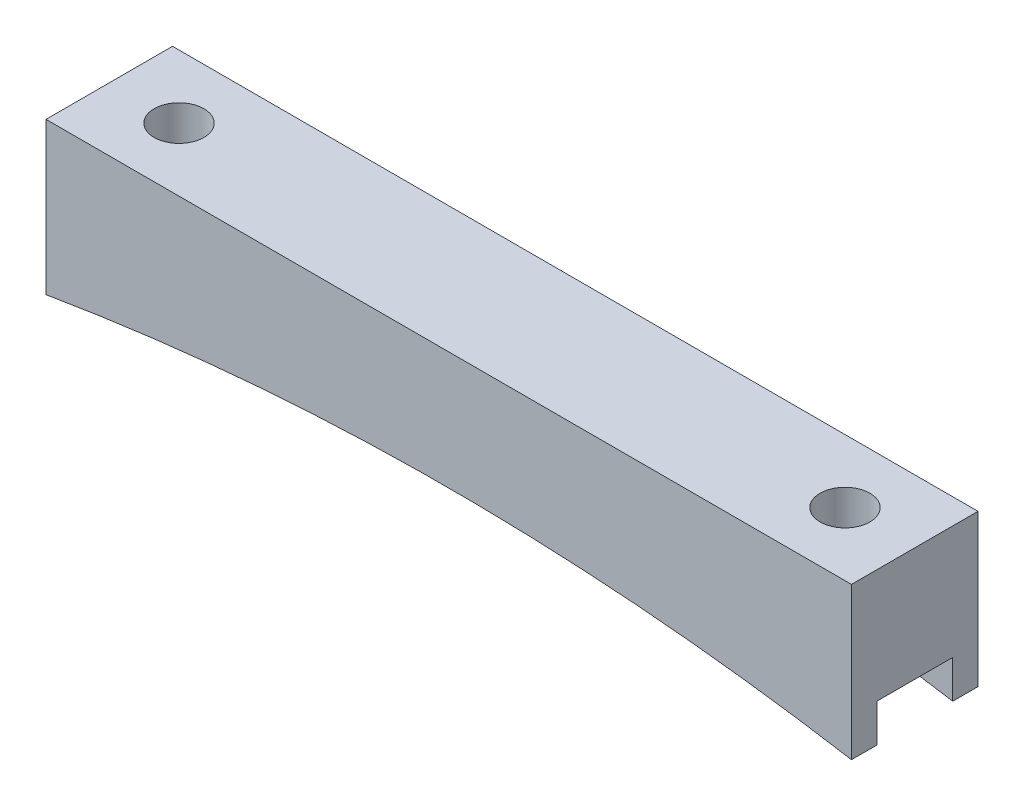
from build123d import *

# Parameters (mm, degrees)
BOSS_EXTRUDE1_DEPTH = 12.7
SKETCH2_R           = 2.5
CUT_EXTRUDE1_DEPTH  = 16.24
SKETCH3_W           = 7.62
SKETCH3_H           = 3.81
CUT_EXTRUDE2_DEPTH  = 81.8409129


with BuildPart() as part:
    # Sketch1 → Boss-Extrude1 (new body)
    with BuildSketch(Plane.XY):
        with BuildLine():
            Line((-40.4204564, 0), (40.4204564, 0))
            Line((40.4204564, 0), (40.4204564, -15.24))
            ThreePointArc((40.4204564, -15.24), (0, -11.830472076), (-40.4204564, -15.24))
            Line((-40.4204564, -15.24), (-40.4204564, 0))
        make_face()
    extrude(amount=BOSS_EXTRUDE1_DEPTH)

    # Sketch2 → Cut-Extrude1 (cut, through all)
    with BuildSketch(Plane(origin=(0, 0, 0), x_dir=(1, 0, 0), z_dir=(0, 1, 0))):
        with Locations((-33.4204564, -6.35)):
            Circle(SKETCH2_R)
        with Locations((33.4204564, -6.35)):
            Circle(SKETCH2_R)
    extrude(amount=-CUT_EXTRUDE1_DEPTH, mode=Mode.SUBTRACT)

    # Sketch3 → Cut-Extrude2 (cut, through all)
    with BuildSketch(Plane(origin=(40.4204564, 0, 0), x_dir=(0, 0, -1), z_dir=(1, 0, 0))):
        with Locations((-6.35, -13.335)):
            Rectangle(SKETCH3_W, SKETCH3_H)
    extrude(amount=-CUT_EXTRUDE2_DEPTH, mode=Mode.SUBTRACT)


solid = part.part
